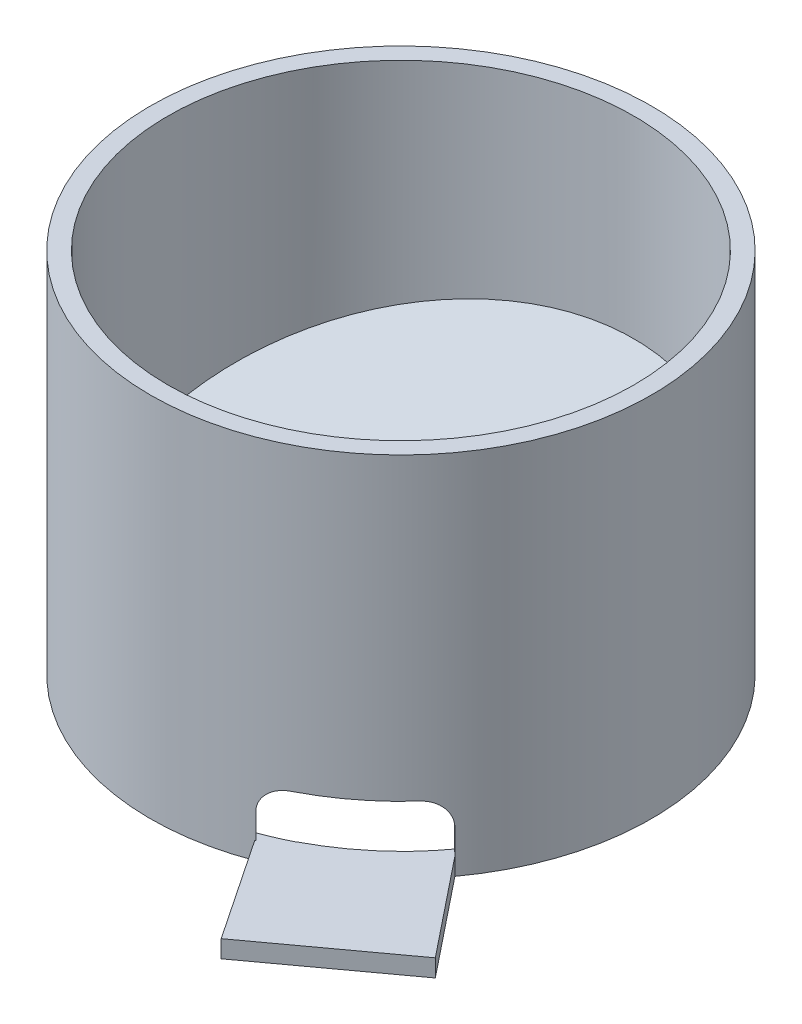
from build123d import *

# Parameters (mm, degrees)
SKETCH1_R                            = 43
SKETCH1_R_2                          = 40
BOSS_EXTRUDE1_DEPTH                  = 63
SKETCH2_R                            = 41.5
SKETCH2_R_2                          = 40
CUT_EXTRUDE1_DEPTH                   = 3
BOSS_EXTRUDE2_REACH                  = 89.561
BOSS_EXTRUDE2_END_RADIUS             = 40
BOSS_EXTRUDE2_DIRECTION_2_REACH      = 89.561
BOSS_EXTRUDE2_DIRECTION_2_END_RADIUS = 40
BOSS_EXTRUDE3_DEPTH                  = 70
CUT_EXTRUDE2_REACH                   = 125.284
CUT_EXTRUDE2_END_RADIUS              = 40
CUT_EXTRUDE3_DEPTH                   = 100.163089401
BOSS_EXTRUDE6_DEPTH                  = 3
CUT_EXTRUDE4_DEPTH                   = 4


with BuildPart() as part:
    # Sketch1 → Boss-Extrude1 (new body)
    with BuildSketch(Plane(origin=(0, 0, 0), x_dir=(1, 0, 0), z_dir=(0, 1, 0))):
        with Locations(Location((0, 0, 0), (0, 0, 270))):
            Circle(SKETCH1_R)
        with Locations(Location((0, 0, 0), (0, 0, 270))):
            Circle(SKETCH1_R_2, mode=Mode.SUBTRACT)
    extrude(amount=BOSS_EXTRUDE1_DEPTH)

    # Sketch2 → Cut-Extrude1 (cut)
    with BuildSketch(Plane(origin=(0, 0, 0), x_dir=(-1, 0, 0), z_dir=(0, -1, 0))):
        with Locations(Location((0, 0, 0), (0, 0, 90))):
            Circle(SKETCH2_R)
        with Locations(Location((0, 0, 0), (0, 0, 90))):
            Circle(SKETCH2_R_2, mode=Mode.SUBTRACT)
    extrude(amount=-CUT_EXTRUDE1_DEPTH, mode=Mode.SUBTRACT)

    # Boss-Extrude2: up to this cylinder (the profile starts inside it)
    boss_extrude2_end = Plane(origin=(0, 21.31795, 0), z_dir=(0, -1, 0)) * Cylinder(BOSS_EXTRUDE2_END_RADIUS, 260.122, mode=Mode.PRIVATE)
    # Sketch4 → Boss-Extrude2 (add, up to the surface)
    with BuildSketch(Plane(origin=(0, 0, 0), x_dir=(0, 0, -1), z_dir=(1, 0, 0)), mode=Mode.PRIVATE) as boss_extrude2_sk1:
        Polygon((-23, 13), (43, 30.6846467), (43, 28.541053161), (-15, 13), align=None)
    boss_extrude2_tool1 = extrude(boss_extrude2_sk1.sketch, amount=-BOSS_EXTRUDE2_REACH, mode=Mode.PRIVATE) & boss_extrude2_end
    add(boss_extrude2_tool1.solids().sort_by_distance((0, 21.31795, -11.956989))[0])

    # Boss-Extrude2 direction 2: up to this cylinder (the profile starts inside it)
    boss_extrude2_direction_2_end = Plane(origin=(0, 21.31795, 0), z_dir=(0, -1, 0)) * Cylinder(BOSS_EXTRUDE2_DIRECTION_2_END_RADIUS, 260.122, mode=Mode.PRIVATE)
    # Sketch4 → Boss-Extrude2 direction 2 (add, up to the surface)
    with BuildSketch(Plane(origin=(0, 0, 0), x_dir=(0, 0, -1), z_dir=(1, 0, 0)), mode=Mode.PRIVATE) as boss_extrude2_direction_2_sk1:
        Polygon((-23, 13), (43, 30.6846467), (43, 28.541053161), (-15, 13), align=None)
    boss_extrude2_direction_2_tool1 = extrude(boss_extrude2_direction_2_sk1.sketch, amount=BOSS_EXTRUDE2_DIRECTION_2_REACH, mode=Mode.PRIVATE) & boss_extrude2_direction_2_end
    add(boss_extrude2_direction_2_tool1.solids().sort_by_distance((0, 21.31795, -11.956989))[0])


with BuildPart() as body_2:
    # Sketch5 → Boss-Extrude3 (new body)
    with BuildSketch(Plane(origin=(0, 63, 0), x_dir=(1, 0, 0), z_dir=(0, 1, 0))):
        Polygon((7.74910462, -54.037683176), (34.954425762, -25.676995378), (36.517040035, -27.175951378), (9.311718893, -55.536639176), align=None)
    extrude(amount=-BOSS_EXTRUDE3_DEPTH)


with BuildPart() as cut_extrude2_tool:
    # Cut-Extrude2: up to this cylinder (the profile starts outside it)
    cut_extrude2_end = Plane(origin=(0, 7.120173, 0), z_dir=(0, -1, 0)) * Cylinder(CUT_EXTRUDE2_END_RADIUS, 331.568, mode=Mode.PRIVATE)
    # Sketch6 → Cut-Extrude2 (new, up to the surface)
    with BuildSketch(Plane(origin=(32.59371092, 0, 31.265898031), x_dir=(0.6922545038449902, 0, -0.7216534500065296), z_dir=(0.7216534500065296, 0, 0.6922545038449902)), mode=Mode.PRIVATE) as cut_extrude2_sk1:
        with BuildLine():
            Line((-18.432533638, 7.25), (-18.432533638, 3))
            Line((-18.432533638, 3), (5.667466362, 3))
            Line((5.667466362, 3), (5.667466362, 7.25))
            ThreePointArc((5.667466362, 7.25), (4.422670182, 10.25520382), (1.417466362, 11.5))
            Line((1.417466362, 11.5), (-14.182533638, 11.5))
            ThreePointArc((-14.182533638, 11.5), (-17.187737458, 10.25520382), (-18.432533638, 7.25))
        make_face()
    cut_extrude2_tool1 = extrude(cut_extrude2_sk1.sketch, amount=-CUT_EXTRUDE2_REACH, mode=Mode.PRIVATE) - cut_extrude2_end
    add(cut_extrude2_tool1.solids().sort_by_distance((28.175373, 7.120173, 35.871875))[0])


with BuildPart() as part_1:
    add(part.part)

    # Cut-Extrude2: cut by cut_extrude2_tool
    add(cut_extrude2_tool.part, mode=Mode.SUBTRACT)

    # Sketch11 → Boss-Extrude6 (add)
    with BuildSketch(Plane(origin=(0, 3, 0), x_dir=(1, 0, 0), z_dir=(0, 1, 0))):
        Polygon((14.90592475, -39.87722305), (34.683715998, -25.417313874), (48.112422428, -42.207782707), (26.881207412, -57.733387396), align=None)
    extrude(amount=-BOSS_EXTRUDE6_DEPTH)

    # Sketch12 → Cut-Extrude4 (cut)
    with BuildSketch(Plane(origin=(0, 0, 0), x_dir=(-1, 0, 0), z_dir=(0, -1, 0))):
        with BuildLine():
            Line((-30.912368333, -27.688857915), (-14.530563251, -38.873033476))
            ThreePointArc((-14.530563251, -38.873033476), (-23.375174905, -34.238453489), (-30.912368333, -27.688857915))
        make_face()
    extrude(amount=-CUT_EXTRUDE4_DEPTH, mode=Mode.SUBTRACT)


with BuildPart() as body_2_1:
    add(body_2.part)

    # Cut-Extrude2: cut by cut_extrude2_tool
    add(cut_extrude2_tool.part, mode=Mode.SUBTRACT)

    # Sketch7 → Cut-Extrude3 (cut, through all)
    with BuildSketch(Plane(origin=(0, 63, 0), x_dir=(1, 0, 0), z_dir=(0, 1, 0))):
        Polygon((34.954425762, -25.676995378), (36.517040035, -27.175951378), (9.311718893, -55.536639176), (7.74910462, -54.037683176), align=None)
    extrude(amount=-CUT_EXTRUDE3_DEPTH, mode=Mode.SUBTRACT)


solid = part_1.part
